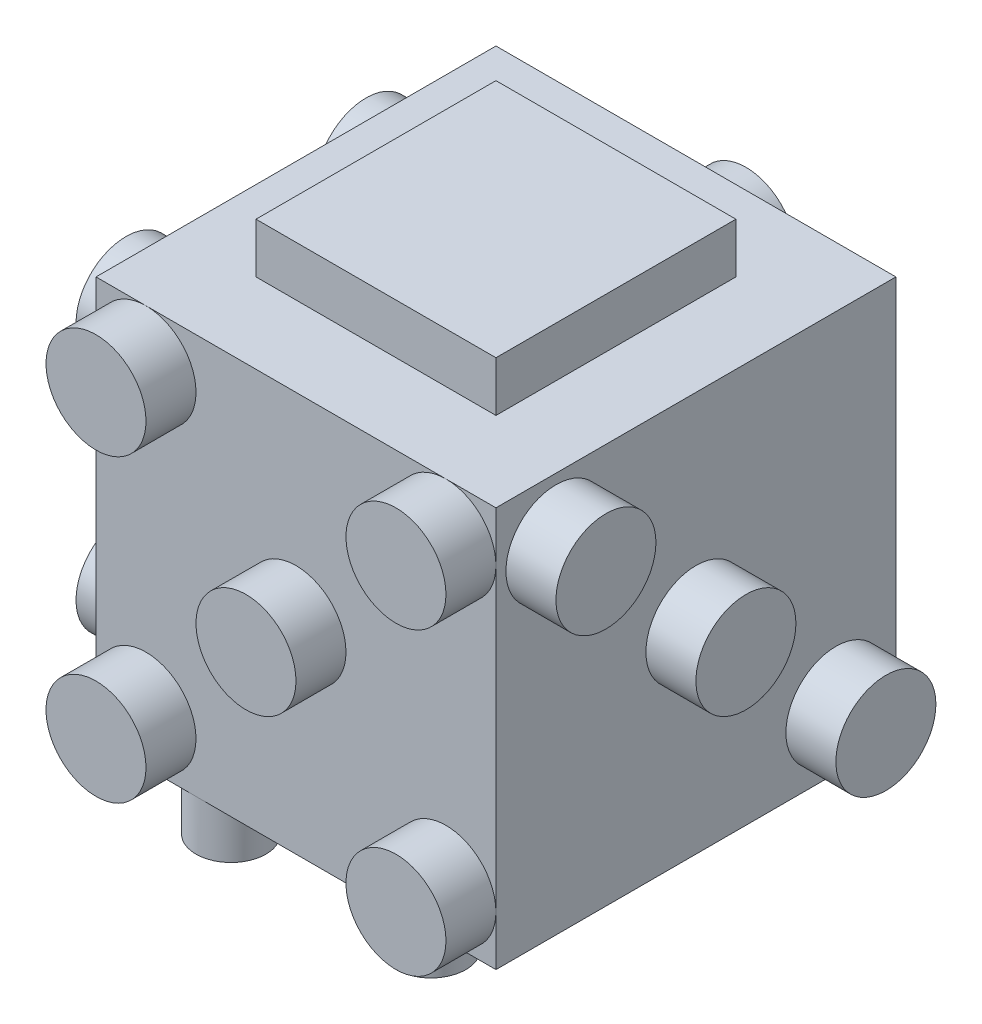
from build123d import *

# Parameters (mm, degrees)
SKETCH1_W             = 25
SKETCH1_H             = 25
BOSS_EXTRUDE1_DEPTH   = 25
SCALE1_SCALE          = 0.8
SKETCH3_R             = 1.75
BOSS_EXTRUDE2_DEPTH   = 2.5
BOSS_EXTRUDE2_2_DEPTH = 2.5
BOSS_EXTRUDE2_3_DEPTH = 2.5
BOSS_EXTRUDE2_4_DEPTH = 2.5
BOSS_EXTRUDE2_5_DEPTH = 2.5
BOSS_EXTRUDE2_6_DEPTH = 2.5
SKETCH7_R             = 2.5
BOSS_EXTRUDE3_DEPTH   = 2.5
SKETCH5_R             = 2.5
BOSS_EXTRUDE4_DEPTH   = 2.5
SKETCH4_R             = 2.5
BOSS_EXTRUDE5_DEPTH   = 2.5
SKETCH2_W             = 12
SKETCH2_H             = 12
BOSS_EXTRUDE7_DEPTH   = 2.5
SKETCH8_R             = 2.5
BOSS_EXTRUDE8_DEPTH   = 10


with BuildPart() as part:
    # Sketch1 → Boss-Extrude1 (new body)
    with BuildSketch(Plane(origin=(0, 0, 0), x_dir=(1, 0, 0), z_dir=(0, 1, 0))):
        Rectangle(SKETCH1_W, SKETCH1_H)
    extrude(amount=BOSS_EXTRUDE1_DEPTH)


with BuildPart() as part_1:
    # Scale1: scaled about (0, 12.5, 0)
    add(part.part.scale(SCALE1_SCALE).moved(Location((0, 2.5, 0))))

    # Sketch7 → Boss-Extrude3 (add)
    with BuildSketch(Plane.XY.offset(12.5)):
        with Locations((-7.5, 20)):
            Circle(SKETCH7_R)
        with Locations((0, 12.5)):
            Circle(SKETCH7_R)
        with Locations((7.5, 20)):
            Circle(SKETCH7_R)
        with Locations((7.5, 5)):
            Circle(SKETCH7_R)
        with Locations((-7.5, 5)):
            Circle(SKETCH7_R)
    extrude(amount=-BOSS_EXTRUDE3_DEPTH)

    # Sketch5 → Boss-Extrude4 (add)
    with BuildSketch(Plane.ZY.offset(12.5)):
        with Locations((-6, 18.5)):
            Circle(SKETCH5_R)
        with Locations((6, 18.5)):
            Circle(SKETCH5_R)
        with Locations((6, 6.5)):
            Circle(SKETCH5_R)
        with Locations((-6, 6.5)):
            Circle(SKETCH5_R)
    extrude(amount=-BOSS_EXTRUDE4_DEPTH)

    # Sketch4 → Boss-Extrude5 (add)
    with BuildSketch(Plane(origin=(12.5, 0, 0), x_dir=(0, 0, -1), z_dir=(1, 0, 0))):
        with Locations((-7, 19.5)):
            Circle(SKETCH4_R)
        with Locations((0, 12.5)):
            Circle(SKETCH4_R)
        with Locations((7, 5.5)):
            Circle(SKETCH4_R)
    extrude(amount=-BOSS_EXTRUDE5_DEPTH)

    # Sketch2 → Boss-Extrude7 (add)
    with BuildSketch(Plane(origin=(0, 25, 0), x_dir=(1, 0, 0), z_dir=(0, 1, 0))):
        Rectangle(SKETCH2_W, SKETCH2_H)
    extrude(amount=-BOSS_EXTRUDE7_DEPTH)

    # Sketch8 → Boss-Extrude8 (add)
    with BuildSketch(Plane(origin=(0, 0, -12.5), x_dir=(-1, 0, 0), z_dir=(0, 0, -1))):
        with Locations((0, 6.5)):
            Circle(SKETCH8_R)
        with Locations((0, 18.5)):
            Circle(SKETCH8_R)
    extrude(amount=-BOSS_EXTRUDE8_DEPTH)


with BuildPart() as body_2:
    # Sketch3 → Boss-Extrude2 (new body)
    with BuildSketch(Plane.XZ):
        with Locations((-5, 8.25)):
            Circle(SKETCH3_R)
    extrude(amount=-BOSS_EXTRUDE2_DEPTH)


with BuildPart() as body_3:
    # Sketch3 → Boss-Extrude2 2 (new body)
    with BuildSketch(Plane.XZ):
        with Locations((-5, 0)):
            Circle(SKETCH3_R)
    extrude(amount=-BOSS_EXTRUDE2_2_DEPTH)


with BuildPart() as body_4:
    # Sketch3 → Boss-Extrude2 3 (new body)
    with BuildSketch(Plane.XZ):
        with Locations((-5, -8.25)):
            Circle(SKETCH3_R)
    extrude(amount=-BOSS_EXTRUDE2_3_DEPTH)


with BuildPart() as body_5:
    # Sketch3 → Boss-Extrude2 4 (new body)
    with BuildSketch(Plane.XZ):
        with Locations((5, 8.25)):
            Circle(SKETCH3_R)
    extrude(amount=-BOSS_EXTRUDE2_4_DEPTH)


with BuildPart() as body_6:
    # Sketch3 → Boss-Extrude2 5 (new body)
    with BuildSketch(Plane.XZ):
        with Locations((5, 0)):
            Circle(SKETCH3_R)
    extrude(amount=-BOSS_EXTRUDE2_5_DEPTH)


with BuildPart() as body_7:
    # Sketch3 → Boss-Extrude2 6 (new body)
    with BuildSketch(Plane.XZ):
        with Locations((5, -8.25)):
            Circle(SKETCH3_R)
    extrude(amount=-BOSS_EXTRUDE2_6_DEPTH)


solid = Compound([part_1.part, body_2.part, body_3.part, body_4.part, body_5.part, body_6.part, body_7.part])
